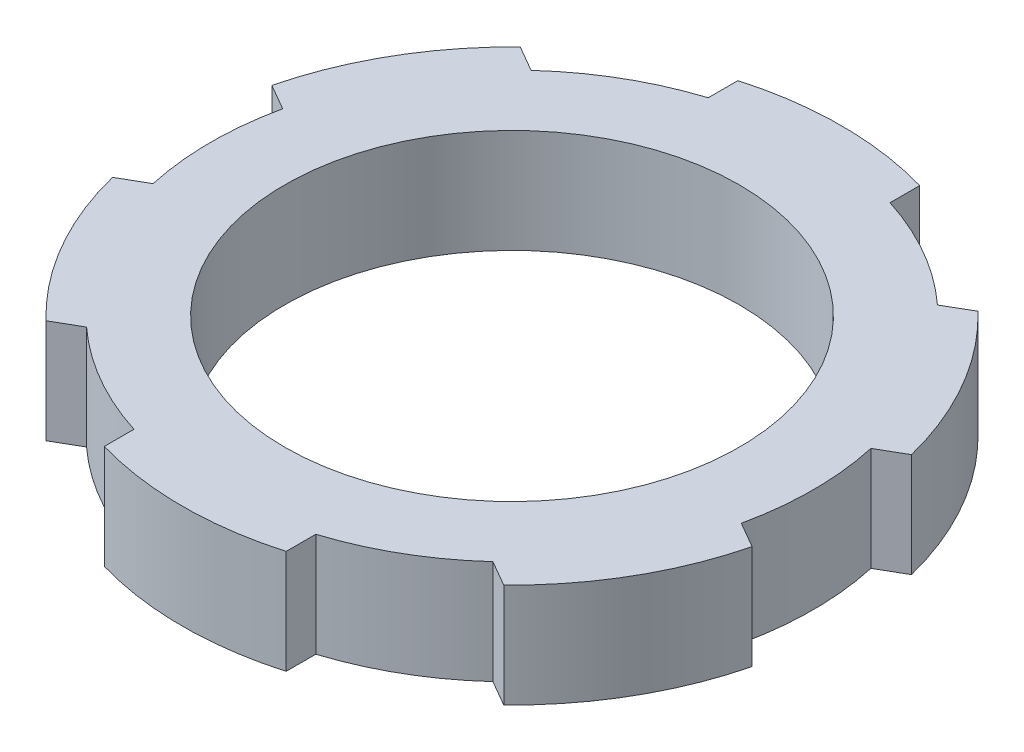
from build123d import *

# Parameters (mm, degrees)
SKETCH1_R           = 13.25
SKETCH1_R_2         = 10
BOSS_EXTRUDE1_DEPTH = 4.572
BOSS_EXTRUDE2_DEPTH = 4.572
CIRPATTERN1_COUNT   = 6


with BuildPart() as part:
    # Sketch1 → Boss-Extrude1 (new body)
    with BuildSketch(Plane(origin=(0, 0, 0), x_dir=(1, 0, 0), z_dir=(0, 1, 0))):
        Circle(SKETCH1_R)
        Circle(SKETCH1_R_2, mode=Mode.SUBTRACT)
    extrude(amount=BOSS_EXTRUDE1_DEPTH)

    # Sketch2 → Boss-Extrude2 (add)
    with BuildSketch(Plane(origin=(0, 4.572, 0), x_dir=(1, 0, 0), z_dir=(0, 1, 0))):
        with BuildLine():
            Line((-4, 12.631805097), (-4, 13.937359865))
            ThreePointArc((-4, 13.937359865), (0, 14.5), (4, 13.937359865))
            Line((4, 13.937359865), (4, 12.631805097))
            ThreePointArc((4, 12.631805097), (0, 13.25), (-4, 12.631805097))
        make_face()
    boss_extrude2 = extrude(amount=-BOSS_EXTRUDE2_DEPTH)

    # CirPattern1: Boss-Extrude2 ×6 about axis
    cirpattern1_axis = Axis((0, 0, 0), (0, 1, 0))
    for i in range(1, CIRPATTERN1_COUNT):
        add(boss_extrude2.rotate(cirpattern1_axis, i * 360 / CIRPATTERN1_COUNT))


solid = part.part
